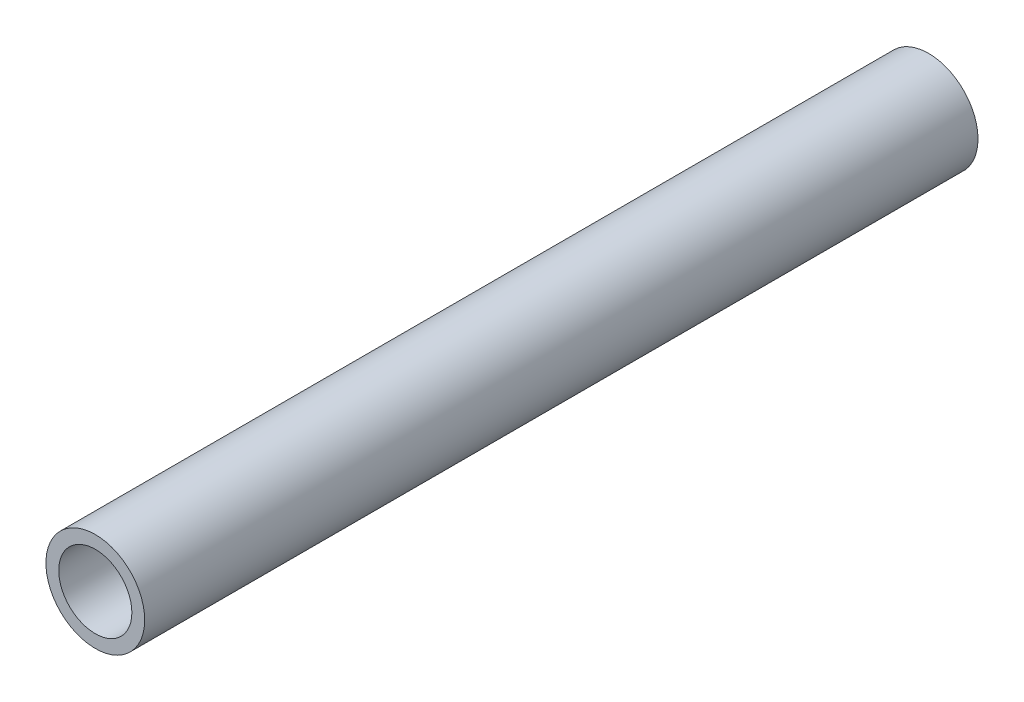
from build123d import *

# Parameters (mm, degrees)
SKETCH1_R           = 10.668
SKETCH1_R_2         = 7.8994
EXTRUDE_THIN1_DEPTH = 90


with BuildPart() as part:
    # Sketch1 → Extrude-Thin1 (new body, symmetric)
    with BuildSketch(Plane.XY):
        Circle(SKETCH1_R)
        Circle(SKETCH1_R_2, mode=Mode.SUBTRACT)
    extrude(amount=EXTRUDE_THIN1_DEPTH, both=True)


solid = part.part
